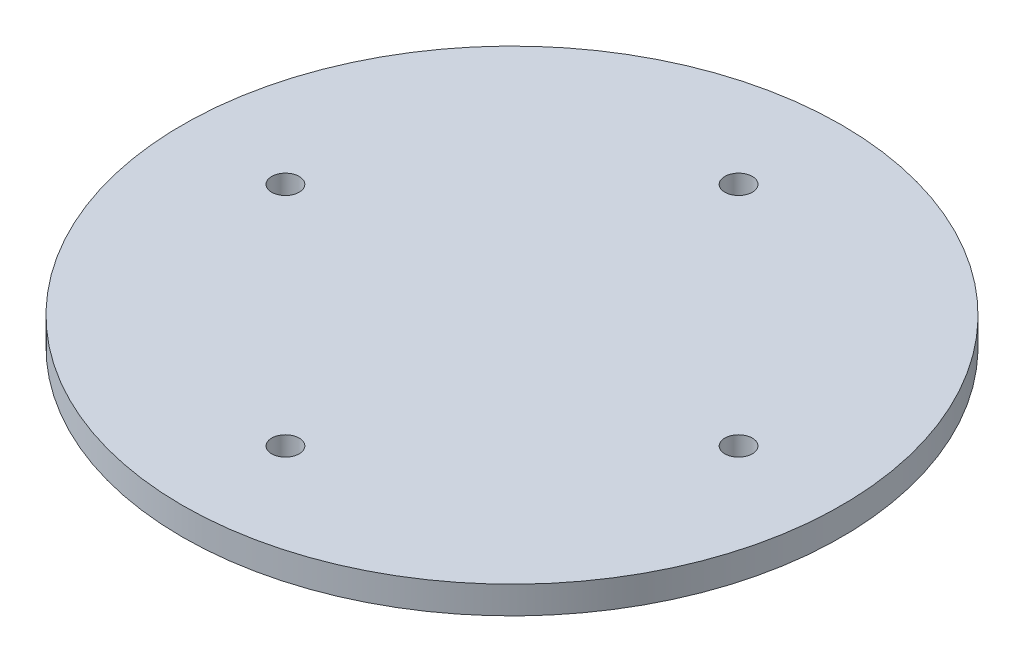
from build123d import *

# Parameters (mm, degrees)
SKETCH1_R           = 60
SKETCH1_R_2         = 2.5
BOSS_EXTRUDE1_DEPTH = 5


with BuildPart() as part:
    # Sketch1 → Boss-Extrude1 (new body)
    with BuildSketch(Plane(origin=(0, 0, 0), x_dir=(1, 0, 0), z_dir=(0, 1, 0))):
        Circle(SKETCH1_R)
        with Locations((0, 41.25)):
            Circle(SKETCH1_R_2, mode=Mode.SUBTRACT)
        with Locations((41.25, 0)):
            Circle(SKETCH1_R_2, mode=Mode.SUBTRACT)
        with Locations((0, -41.25)):
            Circle(SKETCH1_R_2, mode=Mode.SUBTRACT)
        with Locations((-41.25, 0)):
            Circle(SKETCH1_R_2, mode=Mode.SUBTRACT)
    extrude(amount=BOSS_EXTRUDE1_DEPTH)


solid = part.part
